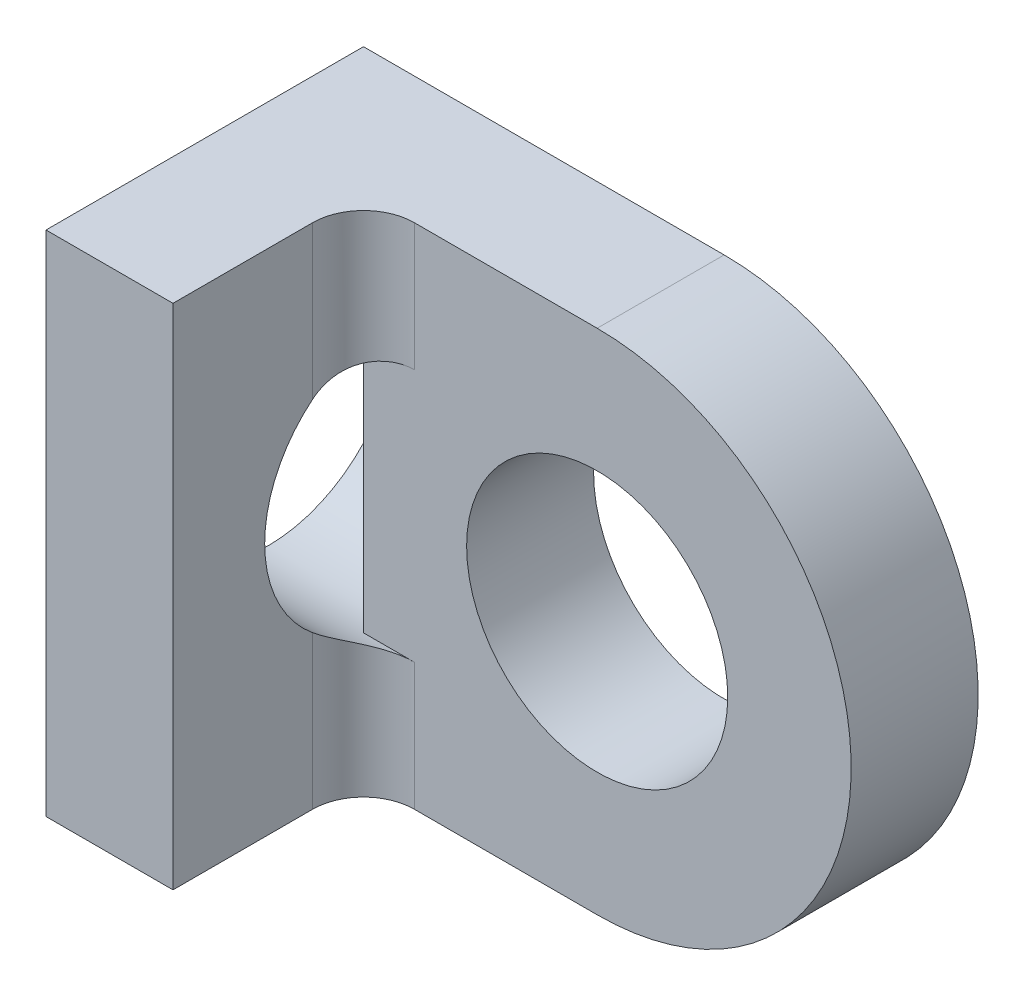
from build123d import *

# Parameters (mm, degrees)
SKETCH1_R           = 3.2639
BOSS_EXTRUDE1_DEPTH = 3.175
SKETCH2_W           = 3.175
SKETCH2_H           = 12.7
BOSS_EXTRUDE2_DEPTH = 4.7625
SKETCH3_R           = 3.2639
CUT_EXTRUDE1_DEPTH  = 3.175
FILLET2_R           = 1.27


with BuildPart() as part:
    # Sketch1 → Boss-Extrude1 (new body)
    with BuildSketch(Plane.XY):
        with BuildLine():
            ThreePointArc((0, 6.35), (6.35, 0), (0, -6.35))
            Line((0, -6.35), (-9.017, -6.35))
            Line((-9.017, -6.35), (-9.017, 6.35))
            Line((-9.017, 6.35), (0, 6.35))
        make_face()
        Circle(SKETCH1_R, mode=Mode.SUBTRACT)
    extrude(amount=BOSS_EXTRUDE1_DEPTH)

    # Sketch2 → Boss-Extrude2 (add)
    with BuildSketch(Plane.XY.offset(3.175)):
        with Locations((-7.4295, 0)):
            Rectangle(SKETCH2_W, SKETCH2_H)
    extrude(amount=BOSS_EXTRUDE2_DEPTH)

    # Sketch3 → Cut-Extrude1 (cut)
    with BuildSketch(Plane.ZY.offset(9.017)):
        with Locations((2.38125, 0)):
            Circle(SKETCH3_R)
    extrude(amount=-CUT_EXTRUDE1_DEPTH, mode=Mode.SUBTRACT)

    # Fillet2
    fillet2_edges = [part.edges().sort_by_distance(p)[0] for p in [
        (-5.842, -4.757956423, 3.175),
        (-5.842, 4.757956423, 3.175),
    ]]
    fillet(fillet2_edges, radius=FILLET2_R)


solid = part.part
